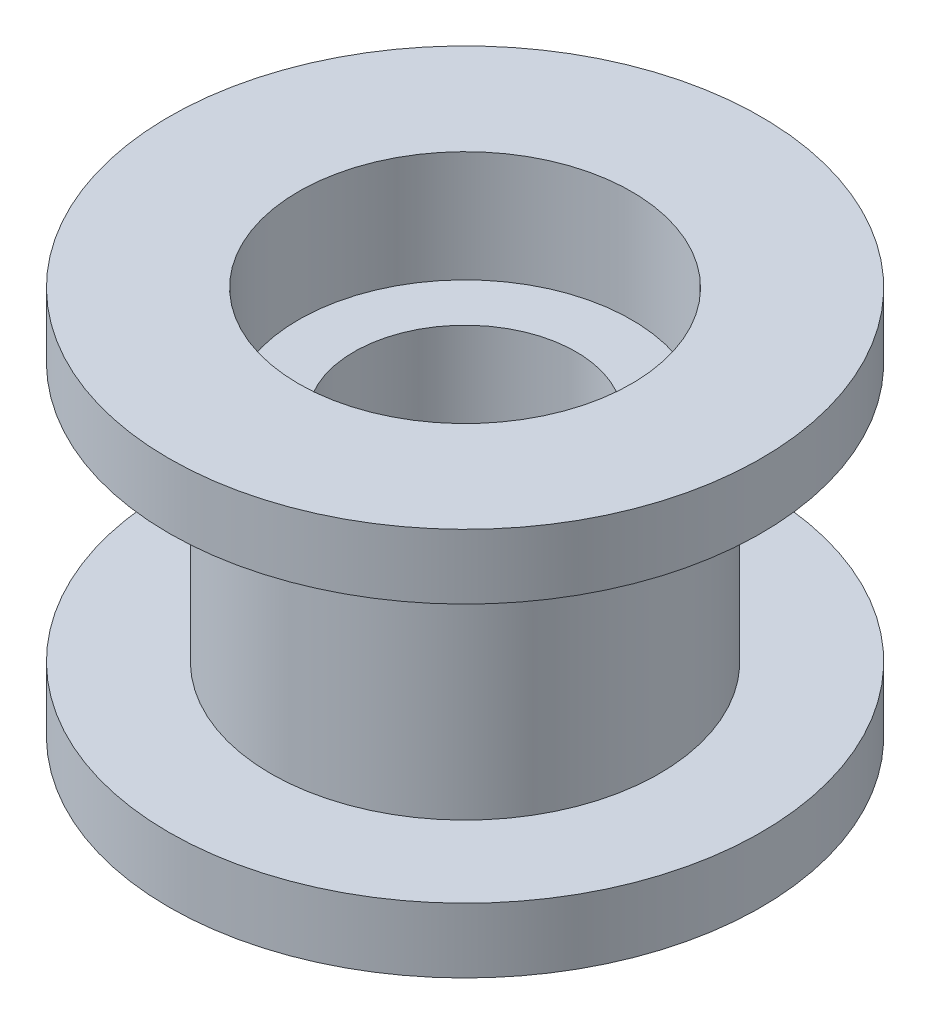
from build123d import *


with BuildPart() as part:
    # Sketch1 → Revolve1 (revolve)
    with BuildSketch(Plane.XY):
        Polygon((-4.5, 0), (-8, 0), (-8, -1.75), (-5.25, -1.75), (-5.25, -8.75), (-8, -8.75), (-8, -10.5), (-4.5, -10.5), (-4.5, -7.5), (-3, -7.5), (-3, -3), (-4.5, -3), align=None)
    revolve(axis=Axis((0, 0, 0), (0, -1, 0)))


solid = part.part
